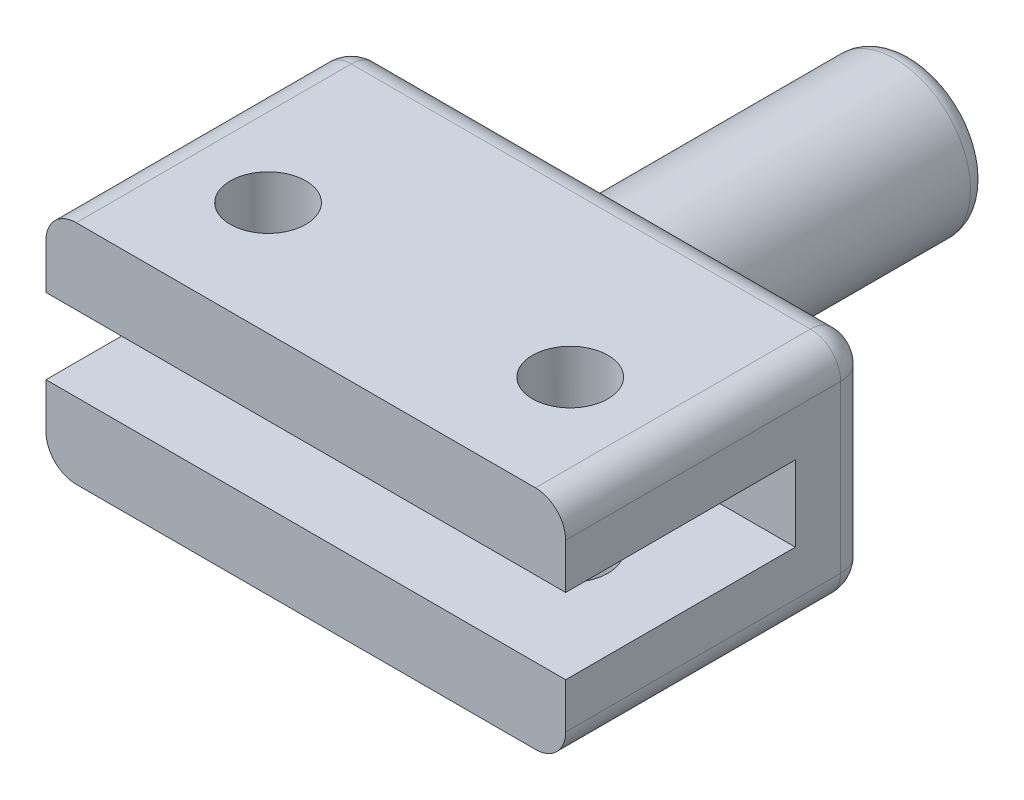
from build123d import *

# Parameters (mm, degrees)
SKETCH1_W           = 3.175
SKETCH1_H           = 12.7
SKETCH2_W           = 21.844
SKETCH2_H           = 9.525
BOSS_EXTRUDE1_DEPTH = 12.827
FILLET4_R           = 1.27
SKETCH3_W           = 9.652
SKETCH3_H           = 3.175
CUT_EXTRUDE1_DEPTH  = 22.844
SKETCH4_R           = 1.5875
CUT_EXTRUDE2_DEPTH  = 10.525
FILLET5_R           = 0.762


with BuildPart() as part:
    # Sketch1 → Revolve1 (revolve)
    with BuildSketch(Plane(origin=(0, 0, 0), x_dir=(1, 0, 0), z_dir=(0, 1, 0))):
        with Locations((1.5875, 6.35)):
            Rectangle(SKETCH1_W, SKETCH1_H)
    revolve(axis=Axis((0, 0, -12.7), (0, 0, 1)))

    # Sketch2 → Boss-Extrude1 (add)
    with BuildSketch(Plane.XY):
        Rectangle(SKETCH2_W, SKETCH2_H)
    extrude(amount=BOSS_EXTRUDE1_DEPTH)

    # Fillet4
    fillet4_edges = [part.edges().sort_by_distance(p)[0] for p in [
        (10.922, -4.7625, 6.4135),
        (0, 4.7625, 0),
        (10.922, 4.7625, 6.4135),
        (-10.922, 0, 0),
        (-10.922, 4.7625, 6.4135),
        (0, -4.7625, 0),
        (-10.922, -4.7625, 6.4135),
        (10.922, 0, 0),
    ]]
    fillet(fillet4_edges, radius=FILLET4_R)

    # Sketch3 → Cut-Extrude1 (cut, through all)
    with BuildSketch(Plane.ZY.offset(10.922)):
        with Locations((8.001, 0)):
            Rectangle(SKETCH3_W, SKETCH3_H)
    extrude(amount=-CUT_EXTRUDE1_DEPTH, mode=Mode.SUBTRACT)

    # Sketch4 → Cut-Extrude2 (cut, through all)
    with BuildSketch(Plane(origin=(0, 4.7625, 0), x_dir=(1, 0, 0), z_dir=(0, 1, 0))):
        with Locations((-6.35, -8.0645)):
            Circle(SKETCH4_R)
        with Locations((6.35, -8.0645)):
            Circle(SKETCH4_R)
    extrude(amount=-CUT_EXTRUDE2_DEPTH, mode=Mode.SUBTRACT)

    # Fillet5
    fillet5_edges = [part.edges().sort_by_distance(p)[0] for p in [
        (-3.175, 0, 0),
        (-3.175, 0, -12.7),
    ]]
    fillet(fillet5_edges, radius=FILLET5_R)


solid = part.part
